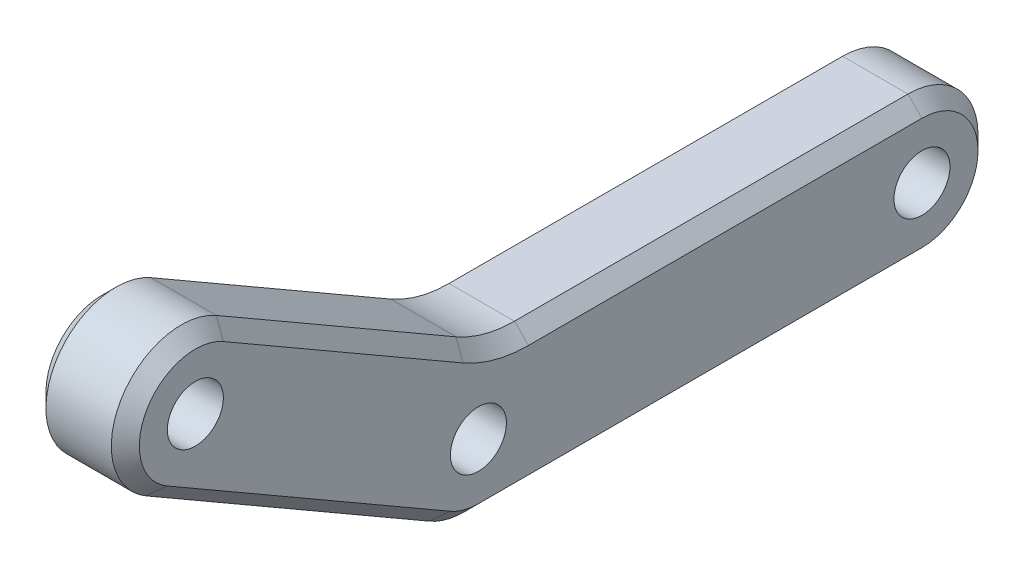
from build123d import *

# Parameters (mm, degrees)
SKETCH_1_R      = 1.2
EXTRUDE_1_DEPTH = 2
FILLET_1_R      = 5
CHAMFER_1_SIZE  = 0.6


with BuildPart() as part:
    # 草图1 → 凸台-拉伸1 (new, symmetric)
    with BuildSketch(Plane(origin=(0, 0, 0), x_dir=(0, 0, -1), z_dir=(1, 0, 0))):
        with BuildLine():
            Line((0, -3), (19, -3))
            ThreePointArc((19, -3), (22, 0), (19, 3))
            Line((19, 3), (0.803847577, 3))
            Line((0.803847577, 3), (-10.624355653, 9.598076211))
            ThreePointArc((-10.624355653, 9.598076211), (-14.722431864, 8.5), (-13.624355653, 4.401923789))
            Line((-13.624355653, 4.401923789), (-1.5, -2.598076211))
            ThreePointArc((-1.5, -2.598076211), (-0.776457135, -2.897777479), (0, -3))
        make_face()
        with Locations((19, 0)):
            Circle(SKETCH_1_R, mode=Mode.SUBTRACT)
        with Locations((-12.124355653, 7)):
            Circle(SKETCH_1_R, mode=Mode.SUBTRACT)
        Circle(SKETCH_1_R, mode=Mode.SUBTRACT)
    extrude(amount=EXTRUDE_1_DEPTH, both=True)

    # 圆角1
    fillet_1_edges = [part.edges().sort_by_distance(p)[0] for p in [
        (0, 3, -0.803847577),
    ]]
    fillet(fillet_1_edges, radius=FILLET_1_R)

    # 倒角1
    chamfer_1_edges = [part.edges().sort_by_distance(p)[0] for p in [
        (-2, 0.901923789, 7.562177826),
        (-2, 8.5, 14.722431864),
        (-2, -2.897777479, 0.776457135),
        (-2, 6.633974596, 5.490381057),
        (-2, -3, -9.5),
        (-2, 3.170370869, -0.849498314),
        (-2, 0, -22),
        (-2, 3, -10.57179677),
        (2, 0.901923789, 7.562177826),
        (2, 8.5, 14.722431864),
        (2, -2.897777479, 0.776457135),
        (2, 6.633974596, 5.490381057),
        (2, -3, -9.5),
        (2, 3.170370869, -0.849498314),
        (2, 0, -22),
        (2, 3, -10.57179677),
    ]]
    chamfer(chamfer_1_edges, length=CHAMFER_1_SIZE)


solid = part.part
